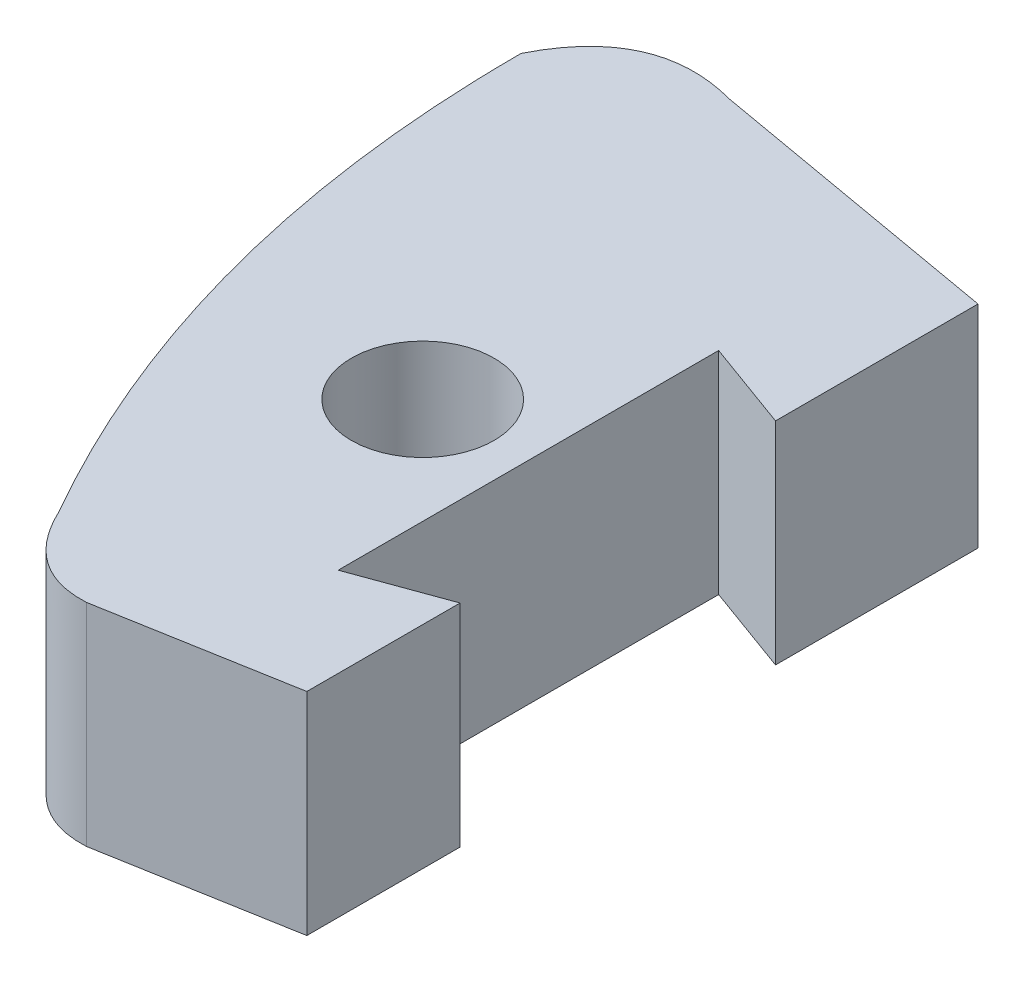
from build123d import *

# Parameters (mm, degrees)
SKETCH1_R           = 0.675
BOSS_EXTRUDE1_DEPTH = 2


with BuildPart() as part:
    # Sketch1 → Boss-Extrude1 (new body)
    with BuildSketch(Plane(origin=(0, 0, 0), x_dir=(1, 0, 0), z_dir=(0, 1, 0))):
        with BuildLine():
            Line((-1.772653955, -0.31256672), (0, 0))
            Line((0, 0), (0, 1.45))
            Line((0, 1.45), (-0.845723359, 1.142181871))
            Line((-0.845723359, 1.142181871), (-0.845723359, 4.742181871))
            Line((-0.845723359, 4.742181871), (0, 4.434363742))
            Line((0, 4.434363742), (0, 6.35))
            Line((0, 6.35), (-2.855942484, 6.853579715))
            add(Edge.make_bspline(
                [(-4.214404462, 6.242429297), (-3.782908861, 7.104554386), (-2.855942484, 6.853579715)],
                knots=[0, 0, 0, 1, 1, 1], degree=2))
            add(Edge.make_bspline(
                [(-2.646853101, 0.302878761), (-4.217046525, 3.042629381), (-4.214404462, 6.242429297)],
                knots=[0, 0, 0, 1, 1, 1], degree=2))
            add(Edge.make_bspline(
                [(-1.772653955, -0.31256672), (-2.342932983, -0.342253748), (-2.646853101, 0.302878761)],
                knots=[0, 0, 0, 1, 1, 1], degree=2))
        make_face()
        with Locations((-1.845723359, 2.942181871)):
            Circle(SKETCH1_R, mode=Mode.SUBTRACT)
    extrude(amount=BOSS_EXTRUDE1_DEPTH)


solid = part.part
